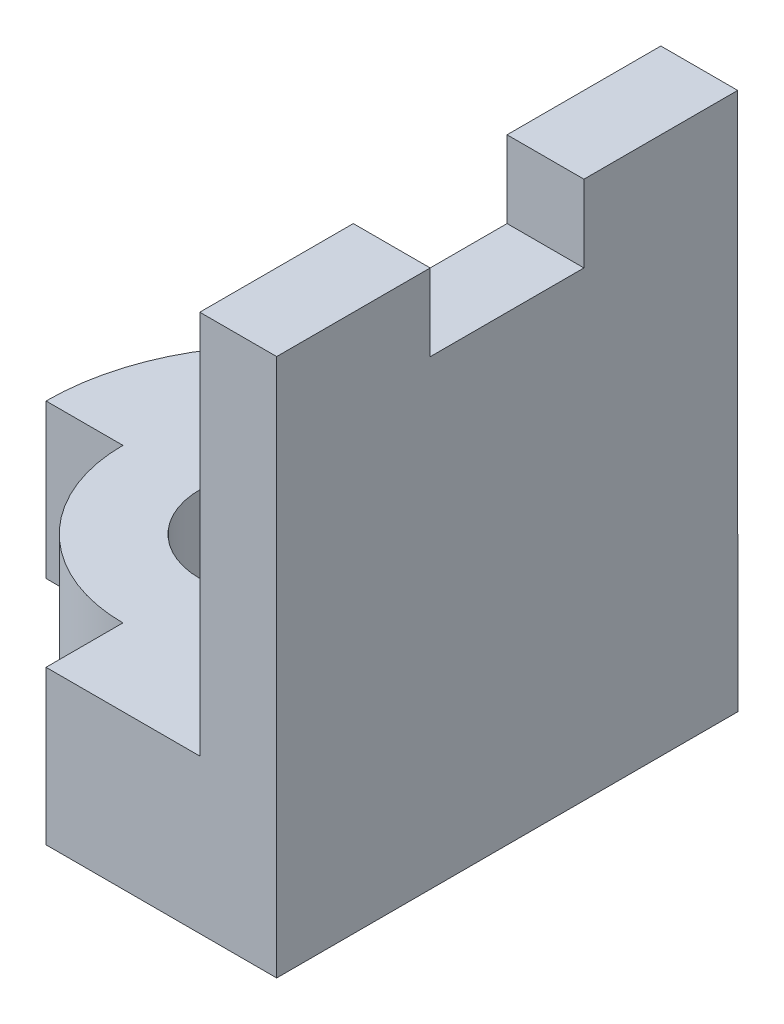
from build123d import *

# Parameters (mm, degrees)
SKETCH1_R           = 1
BOSS_EXTRUDE1_DEPTH = 2
BOSS_EXTRUDE2_DEPTH = 1


with BuildPart() as part:
    # Sketch1 → Boss-Extrude1 (new body)
    with BuildSketch(Plane(origin=(0, 0, 0), x_dir=(1, 0, 0), z_dir=(0, 1, 0))):
        with BuildLine():
            Line((0, -2), (0, -3))
            Line((0, -3), (3, -3))
            Line((3, -3), (3, 3))
            Line((3, 3), (0, 3))
            ThreePointArc((0, 3), (-2.121320344, 2.121320344), (-3, 0))
            Line((-3, 0), (-2, 0))
            ThreePointArc((-2, 0), (-1.414213562, -1.414213562), (0, -2))
        make_face()
        Circle(SKETCH1_R, mode=Mode.SUBTRACT)
    extrude(amount=BOSS_EXTRUDE1_DEPTH)

    # Sketch3 → Boss-Extrude2 (add)
    with BuildSketch(Plane(origin=(3, 0, 0), x_dir=(0, 0, -1), z_dir=(1, 0, 0))):
        Polygon((0.996593321, 7), (2.996593321, 7), (2.996593321, 2), (-3, 2), (-3, 7), (-1.003406679, 7), (-1.003406679, 6), (0.996593321, 6), align=None)
    extrude(amount=-BOSS_EXTRUDE2_DEPTH)


solid = part.part
